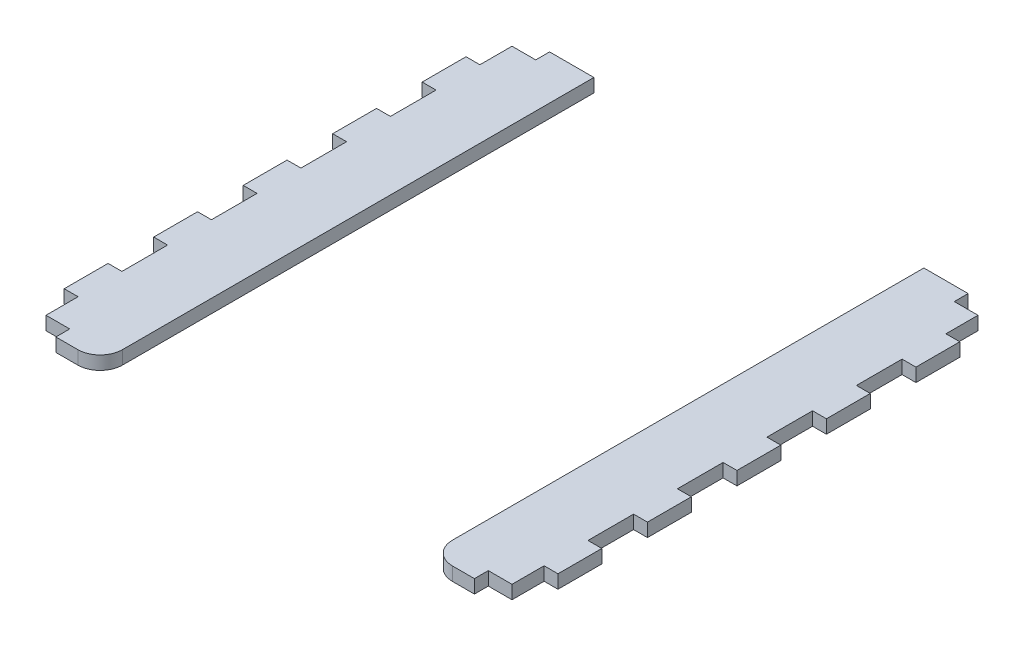
from build123d import *

# Parameters (mm, degrees)
SKETCH1_W             = 18.3
SKETCH1_H             = 110.344434204
BOSS_EXTRUDE1_DEPTH   = 3
BOSS_EXTRUDE1_2_DEPTH = 3
FILLET1_R             = 5
FILLET2_R             = 5
SKETCH3_W             = 3.2
SKETCH3_H             = 10.2
CUT_EXTRUDE1_DEPTH    = 4
SKETCH4_W             = 3.2
SKETCH4_H             = 10.2
CUT_EXTRUDE2_DEPTH    = 4


with BuildPart() as part:
    # Sketch1 → Boss-Extrude1 (new body)
    with BuildSketch(Plane(origin=(0, 0, 0), x_dir=(1, 0, 0), z_dir=(0, 1, 0))):
        with Locations((-46.022217102, 11.670773756)):
            Rectangle(SKETCH1_W, SKETCH1_H)
    extrude(amount=BOSS_EXTRUDE1_DEPTH)

    # Fillet1
    fillet1_edges = [part.edges().sort_by_distance(p)[0] for p in [
        (-36.872217102, 1.5, 43.501443346),
    ]]
    fillet(fillet1_edges, radius=FILLET1_R)

    # Sketch3 → Cut-Extrude1 (cut, through all)
    with BuildSketch(Plane(origin=(0, 0, 0), x_dir=(1, 0, 0), z_dir=(0, 1, 0))):
        Polygon((-52.072217102, -40.401443346), (-46.772217102, -40.401443346), (-46.772217102, -43.601443346), (-55.272217102, -43.601443346), (-55.272217102, -33.229226244), (-52.072217102, -33.229226244), align=None)
        Polygon((-46.772217102, 63.742990858), (-46.772217102, 66.942990858), (-55.272217102, 66.942990858), (-55.272217102, 56.570773756), (-52.072217102, 56.570773756), (-52.072217102, 63.742990858), align=None)
        with Locations((-53.672217102, -18.329226244)):
            Rectangle(SKETCH3_W, SKETCH3_H)
        with Locations((-53.672217102, 1.670773756)):
            Rectangle(SKETCH3_W, SKETCH3_H)
        with Locations((-53.672217102, 21.670773756)):
            Rectangle(SKETCH3_W, SKETCH3_H)
        with Locations((-53.672217102, 41.670773756)):
            Rectangle(SKETCH3_W, SKETCH3_H)
    extrude(amount=CUT_EXTRUDE1_DEPTH, mode=Mode.SUBTRACT)


with BuildPart() as body_2:
    # Sketch1 → Boss-Extrude1 2 (new body)
    with BuildSketch(Plane(origin=(0, 0, 0), x_dir=(1, 0, 0), z_dir=(0, 1, 0))):
        with Locations((46.022217102, 11.670773756)):
            Rectangle(SKETCH1_W, SKETCH1_H)
    extrude(amount=BOSS_EXTRUDE1_2_DEPTH)

    # Fillet2
    fillet2_edges = [body_2.edges().sort_by_distance(p)[0] for p in [
        (36.872217102, 1.5, 43.501443346),
    ]]
    fillet(fillet2_edges, radius=FILLET2_R)

    # Sketch4 → Cut-Extrude2 (cut, through all)
    with BuildSketch(Plane(origin=(0, 0, 0), x_dir=(1, 0, 0), z_dir=(0, 1, 0))):
        with Locations((53.672217102, 41.670773756)):
            Rectangle(SKETCH4_W, SKETCH4_H)
        with Locations((53.672217102, 21.670773756)):
            Rectangle(SKETCH4_W, SKETCH4_H)
        with Locations((53.672217102, -18.329226244)):
            Rectangle(SKETCH4_W, SKETCH4_H)
        with Locations((53.672217102, 1.670773756)):
            Rectangle(SKETCH4_W, SKETCH4_H)
        Polygon((52.072217102, -40.401443346), (52.072217102, -33.229226244), (55.272217102, -33.229226244), (55.272217102, -43.601443346), (46.772217102, -43.601443346), (46.772217102, -40.401443346), align=None)
        Polygon((52.072217102, 63.742990858), (46.772217102, 63.742990858), (46.772217102, 66.942990858), (55.272217102, 66.942990858), (55.272217102, 56.570773756), (52.072217102, 56.570773756), align=None)
    extrude(amount=CUT_EXTRUDE2_DEPTH, mode=Mode.SUBTRACT)


solid = Compound([part.part, body_2.part])
